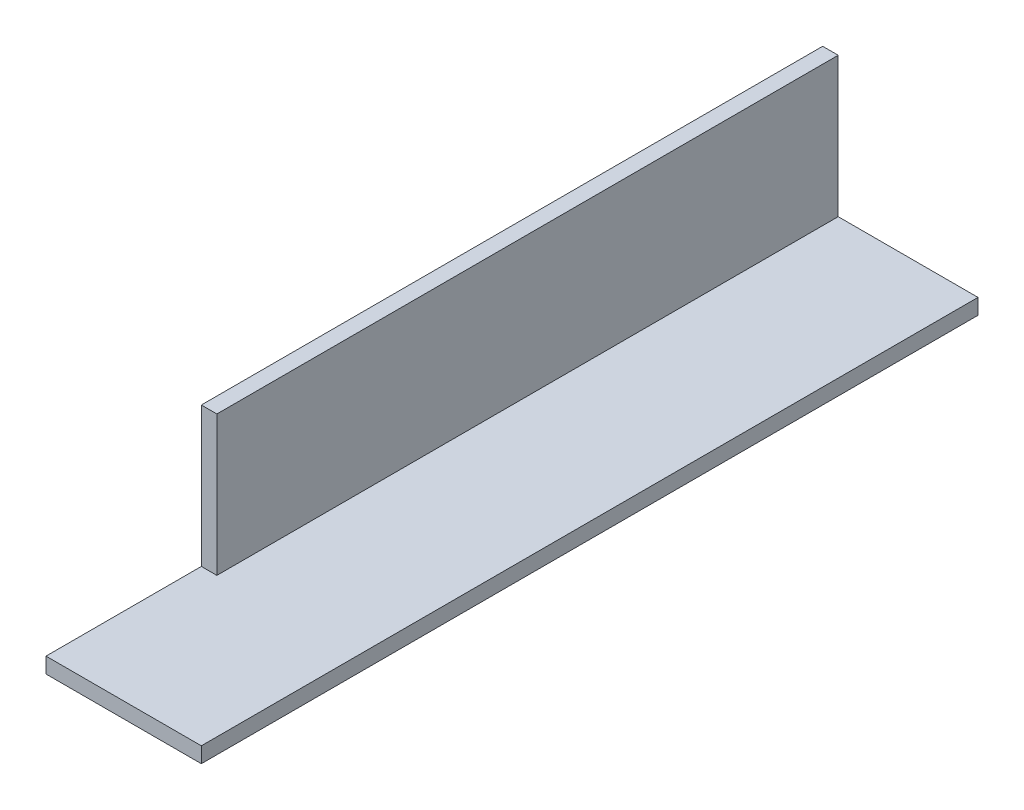
from build123d import *

# Parameters (mm, degrees)
BOSS_EXTRUDE1_DEPTH = 100
SKETCH3_W           = 20
SKETCH3_H           = 18
CUT_EXTRUDE2_DEPTH  = 3


with BuildPart() as part:
    # Sketch1 → Boss-Extrude1 (new body)
    with BuildSketch(Plane.XY):
        Polygon((0, 0), (0, 20), (2, 20), (2, 2), (20, 2), (20, 0), align=None)
    extrude(amount=BOSS_EXTRUDE1_DEPTH)

    # Sketch3 → Cut-Extrude2 (cut, through all)
    with BuildSketch(Plane(origin=(2, 0, 0), x_dir=(0, 0, -1), z_dir=(1, 0, 0))):
        with Locations((-90, 11)):
            Rectangle(SKETCH3_W, SKETCH3_H)
    extrude(amount=-CUT_EXTRUDE2_DEPTH, mode=Mode.SUBTRACT)


solid = part.part
